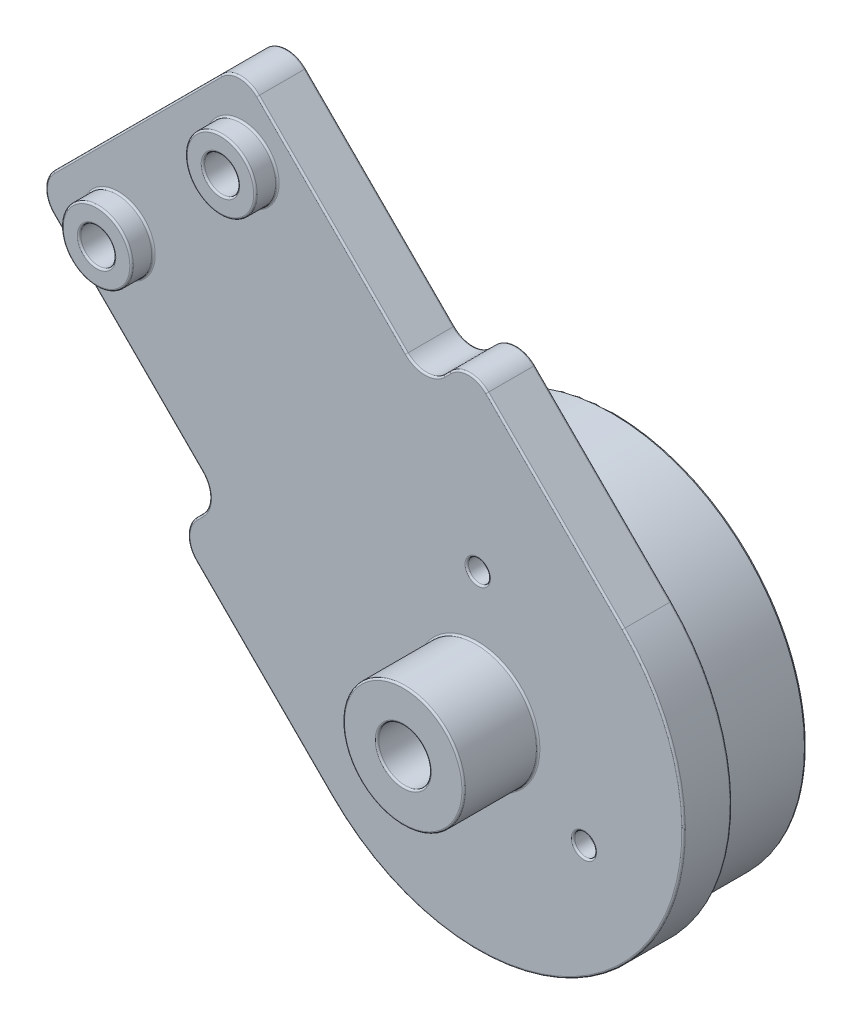
from build123d import *

# Parameters (mm, degrees)
SKETCH6_R           = 10
SKETCH6_R_2         = 1
BOSS_EXTRUDE1_DEPTH = 2.75
SKETCH7_R           = 10
BOSS_EXTRUDE2_DEPTH = 1
SKETCH9_R           = 11
SKETCH9_R_2         = 10
BOSS_EXTRUDE3_DEPTH = 5
FILLET1_R           = 1.5
SKETCH10_R          = 2
SKETCH10_R_2        = 1
BOSS_EXTRUDE4_DEPTH = 1.25
SKETCH11_R          = 1.5
CUT_EXTRUDE1_DEPTH  = 1
SKETCH12_R          = 3.45
SKETCH12_R_2        = 1.5
BOSS_EXTRUDE5_DEPTH = 4.25
SKETCH13_R          = 0.625
CUT_EXTRUDE2_DEPTH  = 1
FILLET2_R           = 0.1


with BuildPart() as part:
    # Sketch6 → Boss-Extrude1 (new body)
    with BuildSketch(Plane.XY):
        with BuildLine():
            Line((86.388194462, 25.279067427), (74.720932573, 13.611805538))
            Line((74.720932573, 13.611805538), (85.32753429, 3.00520382))
            Line((85.32753429, 3.00520382), (82.852660556, 0.530330086))
            Line((82.852660556, 0.530330086), (91.691495321, -8.308504679))
            ThreePointArc((91.691495321, -8.308504679), (108.308504679, -8.308504679), (108.308504679, 8.308504679))
            Line((108.308504679, 8.308504679), (99.469669914, 17.147339444))
            Line((99.469669914, 17.147339444), (96.99479618, 14.67246571))
            Line((96.99479618, 14.67246571), (86.388194462, 25.279067427))
        make_face()
        with Locations((100, 0)):
            Circle(SKETCH6_R, mode=Mode.SUBTRACT)
        with Locations((86.564971157, 20.506096654)):
            Circle(SKETCH6_R_2, mode=Mode.SUBTRACT)
        with Locations((79.493903346, 13.435028843)):
            Circle(SKETCH6_R_2, mode=Mode.SUBTRACT)
    extrude(amount=BOSS_EXTRUDE1_DEPTH)

    # Sketch7 → Boss-Extrude2 (add)
    with BuildSketch(Plane.XY.offset(2.75)):
        with Locations((100, 0)):
            Circle(SKETCH7_R)
    extrude(amount=-BOSS_EXTRUDE2_DEPTH)

    # Sketch9 → Boss-Extrude3 (add)
    with BuildSketch(Plane(origin=(0, 0, 0), x_dir=(-1, 0, 0), z_dir=(0, 0, -1))):
        with Locations((-100, 0)):
            Circle(SKETCH9_R)
        with Locations((-100, 0)):
            Circle(SKETCH9_R_2, mode=Mode.SUBTRACT)
    extrude(amount=BOSS_EXTRUDE3_DEPTH)

    # Fillet1
    fillet1_edges = [part.edges().sort_by_distance(p)[0] for p in [
        (96.99479618, 14.67246571, 1.375),
        (99.469669914, 17.147339444, 1.375),
        (82.852660556, 0.530330086, 1.375),
        (85.32753429, 3.00520382, 1.375),
        (74.720932573, 13.611805538, 1.375),
        (86.388194462, 25.279067427, 1.375),
    ]]
    fillet(fillet1_edges, radius=FILLET1_R)

    # Sketch10 → Boss-Extrude4 (add)
    with BuildSketch(Plane.XY.offset(2.75)):
        with Locations((79.493903346, 13.435028843)):
            Circle(SKETCH10_R)
        with Locations((79.493903346, 13.435028843)):
            Circle(SKETCH10_R_2, mode=Mode.SUBTRACT)
        with Locations((86.564971157, 20.506096654)):
            Circle(SKETCH10_R)
        with Locations((86.564971157, 20.506096654)):
            Circle(SKETCH10_R_2, mode=Mode.SUBTRACT)
    extrude(amount=BOSS_EXTRUDE4_DEPTH)

    # Sketch11 → Cut-Extrude1 (cut)
    with BuildSketch(Plane.XY.offset(2.75)):
        with Locations((100, 0)):
            Circle(SKETCH11_R)
    extrude(amount=-CUT_EXTRUDE1_DEPTH, mode=Mode.SUBTRACT)

    # Sketch12 → Boss-Extrude5 (add)
    with BuildSketch(Plane.XY.offset(2.75)):
        with Locations((100, 0)):
            Circle(SKETCH12_R)
        with Locations((100, 0)):
            Circle(SKETCH12_R_2, mode=Mode.SUBTRACT)
    extrude(amount=BOSS_EXTRUDE5_DEPTH)

    # Sketch13 → Cut-Extrude2 (cut)
    with BuildSketch(Plane.XY.offset(2.75)):
        with Locations((100, 7)):
            Circle(SKETCH13_R)
        with Locations((106.062177826, -3.5)):
            Circle(SKETCH13_R)
        with Locations((93.937822174, -3.5)):
            Circle(SKETCH13_R)
    extrude(amount=-CUT_EXTRUDE2_DEPTH, mode=Mode.SUBTRACT)

    # Fillet2
    fillet2_edges = [part.edges().sort_by_distance(p)[0] for p in [
        (84.564971157, 20.506096654, 4),
        (84.564971157, 20.506096654, 2.75),
        (85.564971157, 20.506096654, 4),
        (98.5, 0, 1.75),
        (96.55, 0, 7),
        (96.55, 0, 2.75),
        (98.5, 0, 7),
        (99.375, 7, 2.75),
        (99.375, 7, 1.75),
        (105.437177826, -3.5, 2.75),
        (105.437177826, -3.5, 1.75),
        (93.312822174, -3.5, 2.75),
        (93.312822174, -3.5, 1.75),
        (108.308504679, -8.308504679, 2.75),
        (85.564971157, 20.506096654, 0),
        (104.419417382, 12.197591975, 2.75),
        (78.493903346, 13.435028843, 0),
        (90, 0, 1.75),
        (111, 0, 0),
        (111, 0, -5),
        (110, 0, -5),
        (91.691495321, 19.975766569, 0),
        (91.691495321, 19.975766569, 2.75),
        (98.232233047, 15.909902577, 0),
        (98.232233047, 15.909902577, 2.75),
        (87.802408025, -4.419417382, 0),
        (84.090097423, 1.767766953, 0),
        (80.024233431, 8.308504679, 0),
        (80.554563517, 19.445436483, 0),
        (86.388194462, 24.657747084, 0),
        (75.342252916, 13.611805538, 0),
        (83.4739809, 0.530330086, 0),
        (99.469669914, 16.5260191, 0),
        (80.554563517, 19.445436483, 2.75),
        (80.024233431, 8.308504679, 2.75),
        (84.090097423, 1.767766953, 2.75),
        (87.802408025, -4.419417382, 2.75),
        (86.388194462, 24.657747084, 2.75),
        (75.342252916, 13.611805538, 2.75),
        (83.4739809, 0.530330086, 2.75),
        (99.469669914, 16.5260191, 2.75),
        (96.99479618, 15.293786053, 0),
        (96.99479618, 15.293786053, 2.75),
        (84.706213947, 3.00520382, 0),
        (84.706213947, 3.00520382, 2.75),
        (104.419417382, 12.197591975, 0),
        (108.308504679, -8.308504679, 0),
        (77.493903346, 13.435028843, 4),
        (77.493903346, 13.435028843, 2.75),
        (78.493903346, 13.435028843, 4),
    ]]
    fillet(fillet2_edges, radius=FILLET2_R)


solid = part.part
